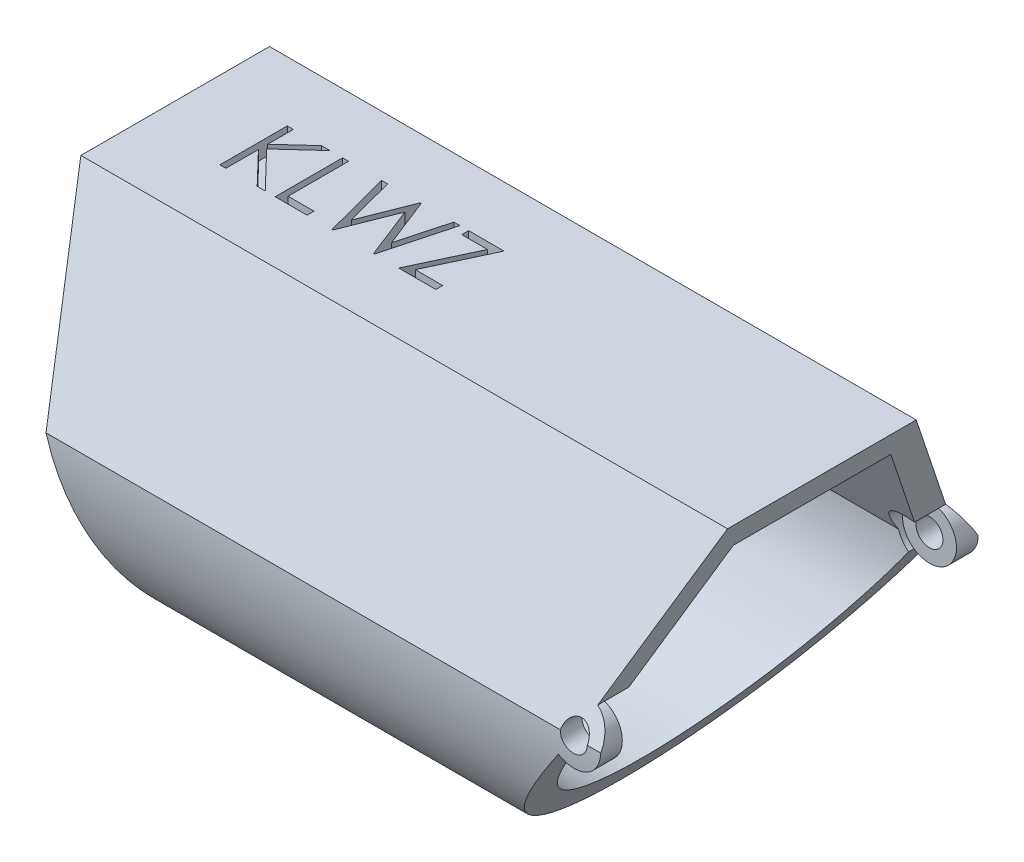
from build123d import *

# Parameters (mm, degrees)
BOSS_EXTRUDE1_DEPTH     = 30.48
SHELL1_T                = -1.27
SKETCH2_R               = 0.635
CUT_EXTRUDE1_DEPTH      = 9.904502457
CUT_EXTRUDE1_DEPTH_BACK = 9.904502457
SKETCH5_R               = 1.27
CUT_EXTRUDE3_DEPTH      = 7.874
CUT_EXTRUDE3_DEPTH_BACK = 7.874
SKETCH6_W               = 1.960613331
SKETCH6_H               = 2.54
CUT_EXTRUDE4_DEPTH      = 0.508
CUT_EXTRUDE2_DEPTH      = 0.762


with BuildPart() as part:
    # Sketch1 → Boss-Extrude1 (new body)
    with BuildSketch(Plane(origin=(0, 0, 0), x_dir=(0, 0, -1), z_dir=(1, 0, 0))):
        with BuildLine():
            Line((-4.445, 0), (4.445, 0))
            Line((4.445, 0), (8.89, -7.69896584))
            ThreePointArc((8.89, -7.69896584), (0, -17.111468296), (-8.89, -7.69896584))
            Line((-8.89, -7.69896584), (-4.445, 0))
        make_face()
    extrude(amount=BOSS_EXTRUDE1_DEPTH)

    # Shell1
    shell1_openings = [part.faces().sort_by_distance(p)[0] for p in [
        (30.48, -6.202608534, 0),
        (0, -6.202608534, 0),
    ]]
    offset(amount=SHELL1_T, openings=shell1_openings, kind=Kind.INTERSECTION)

    # Sketch2 → Cut-Extrude1 (cut, two sides)
    with BuildSketch(Plane.XY) as cut_extrude1_sk:
        with Locations((27.6778056, -7.69896584)):
            Circle(SKETCH2_R)
        with BuildLine():
            Line((30.48, 0), (28.112171182, -6.505556211))
            ThreePointArc((28.112171182, -6.505556211), (28.804309358, -8.285386578), (26.949363526, -8.739288936))
            Line((26.949363526, -8.739288936), (21.087100426, -17.111468296))
            Line((21.087100426, -17.111468296), (30.48, -17.111468296))
            Line((30.48, -17.111468296), (30.48, 0))
        make_face()
        Polygon((0, -17.111468296), (6.228065124, -17.111468296), (0, 0), align=None)
    extrude(amount=CUT_EXTRUDE1_DEPTH, mode=Mode.SUBTRACT)
    extrude(cut_extrude1_sk.sketch, amount=-CUT_EXTRUDE1_DEPTH_BACK, mode=Mode.SUBTRACT)

    # Sketch5 → Cut-Extrude3 (cut, two sides)
    with BuildSketch(Plane.XY) as cut_extrude3_sk:
        with Locations((27.6778056, -7.69896584)):
            Circle(SKETCH5_R)
    extrude(amount=CUT_EXTRUDE3_DEPTH, mode=Mode.SUBTRACT)
    extrude(cut_extrude3_sk.sketch, amount=-CUT_EXTRUDE3_DEPTH_BACK, mode=Mode.SUBTRACT)

    # Sketch6 → Cut-Extrude4 (cut)
    with BuildSketch(Plane(origin=(0, -17.111468296, 0), x_dir=(1, 0, 0), z_dir=(0, 1, 0))):
        with Locations((6.009758459, 0)):
            Rectangle(SKETCH6_W, SKETCH6_H)
    extrude(amount=CUT_EXTRUDE4_DEPTH, mode=Mode.SUBTRACT)

    # Sketch3 → Cut-Extrude2 (cut)
    with BuildSketch(Plane(origin=(0, 0, 0), x_dir=(1, 0, 0), z_dir=(0, 1, 0))):
        Polygon((3.659953748, 1.62282455), (3.944889646, 1.62282455), (3.944889646, 0.413755039), (5.26844233, 1.62282455), (5.674857594, 1.62282455), (4.114706352, 0.198145063), (5.796972979, -1.55217545), (5.417270455, -1.55217545), (3.944889646, -0.020008984), (3.944889646, -1.55217545), (3.659953748, -1.55217545), align=None)
        Polygon((6.265081953, 1.62282455), (6.550017851, 1.62282455), (6.550017851, -1.226534424), (7.771171697, -1.226534424), (7.771171697, -1.55217545), (6.265081953, -1.55217545), align=None)
        Polygon((8.096812723, 1.62282455), (8.391288884, 1.62282455), (9.012678107, -0.705635987), (9.936811721, 1.62282455), (9.978152867, 1.62282455), (10.885114005, -0.689735546), (11.509683316, 1.62282455), (11.800979389, 1.62282455), (10.944899662, -1.55217545), (10.904194533, -1.55217545), (9.948896056, 0.876139855), (8.982149261, -1.55217545), (8.941444133, -1.55217545), align=None)
        Polygon((12.208030671, 1.297183524), (12.208030671, 1.62282455), (13.876940928, 1.62282455), (12.545120014, -1.226534424), (13.8362358, -1.226534424), (13.8362358, -1.55217545), (12.085915287, -1.55217545), (13.4177362, 1.297183524), align=None)
    extrude(amount=-CUT_EXTRUDE2_DEPTH, mode=Mode.SUBTRACT)


solid = part.part
